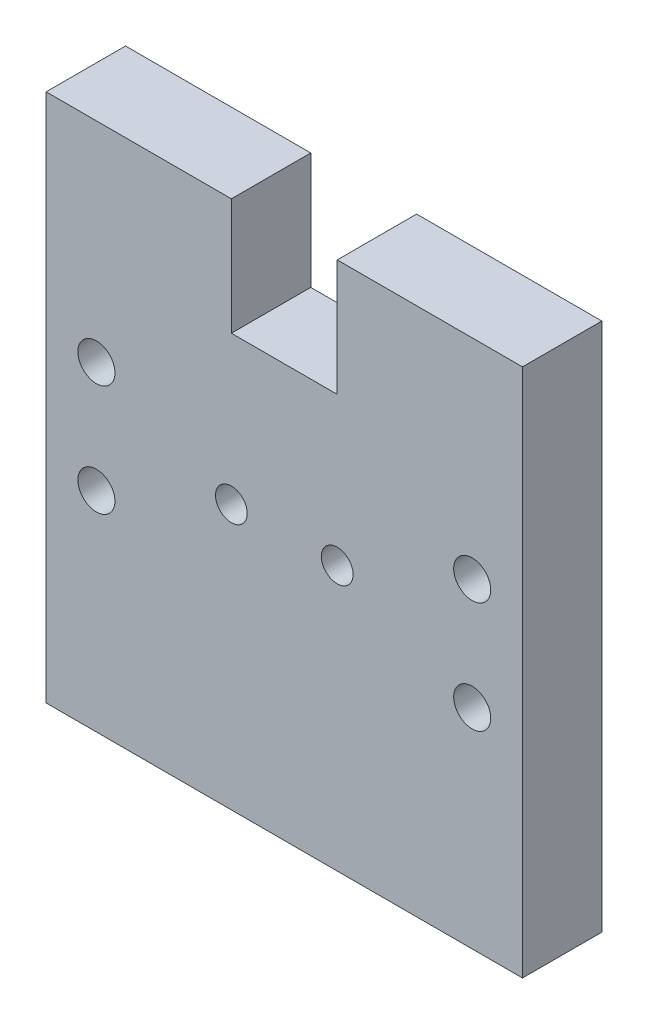
from build123d import *

# Parameters (mm, degrees)
SKETCH1_W           = 90
SKETCH1_H           = 100
SKETCH1_R           = 3
SKETCH1_R_2         = 3.5
BOSS_EXTRUDE1_DEPTH = 15
SKETCH2_W           = 20
SKETCH2_H           = 22
CUT_EXTRUDE1_DEPTH  = 15


with BuildPart() as part:
    # Sketch1 → Boss-Extrude1 (new body)
    with BuildSketch(Plane.XY):
        with Locations((250.418436726, 76.333548914)):
            Rectangle(SKETCH1_W, SKETCH1_H)
        with Locations((260.418436726, 76.333548914)):
            Circle(SKETCH1_R, mode=Mode.SUBTRACT)
        with Locations((240.418436726, 76.333548914)):
            Circle(SKETCH1_R, mode=Mode.SUBTRACT)
        with Locations((214.918436726, 86.833548914)):
            Circle(SKETCH1_R_2, mode=Mode.SUBTRACT)
        with Locations((214.918436726, 65.833548914)):
            Circle(SKETCH1_R_2, mode=Mode.SUBTRACT)
        with Locations((285.918436726, 86.833548914)):
            Circle(SKETCH1_R_2, mode=Mode.SUBTRACT)
        with Locations((285.918436726, 65.833548914)):
            Circle(SKETCH1_R_2, mode=Mode.SUBTRACT)
    extrude(amount=BOSS_EXTRUDE1_DEPTH)

    # Sketch2 → Cut-Extrude1 (cut)
    with BuildSketch(Plane.XY.offset(15)):
        with Locations((250.418436726, 115.333548914)):
            Rectangle(SKETCH2_W, SKETCH2_H)
    extrude(amount=-CUT_EXTRUDE1_DEPTH, mode=Mode.SUBTRACT)


solid = part.part
